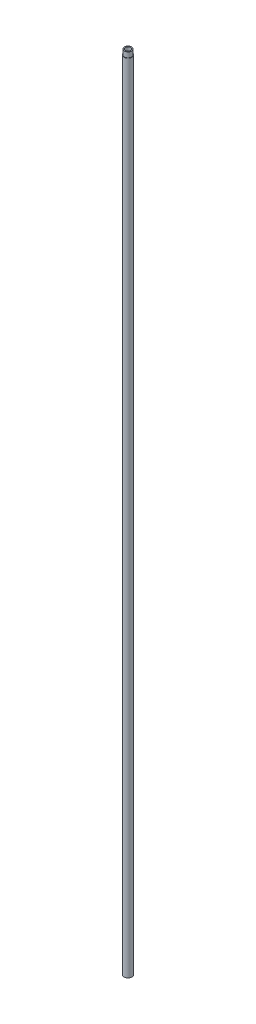
from build123d import *


with BuildPart() as part:
    # Croquis1 → Revolución1 (revolve)
    with BuildSketch(Plane.XY):
        Polygon((3.16, 34.140689655), (4.26, 34.140689655), (4.26, 28.140689655), (4.76, 28.140689655), (4.76, -905.859310345), (3.76, -905.859310345), (3.76, -897.859310345), (3.16, -897.859310345), align=None)
    revolve(axis=Axis((0, 37.259310345, 0), (0, -1, 0)))


solid = part.part
